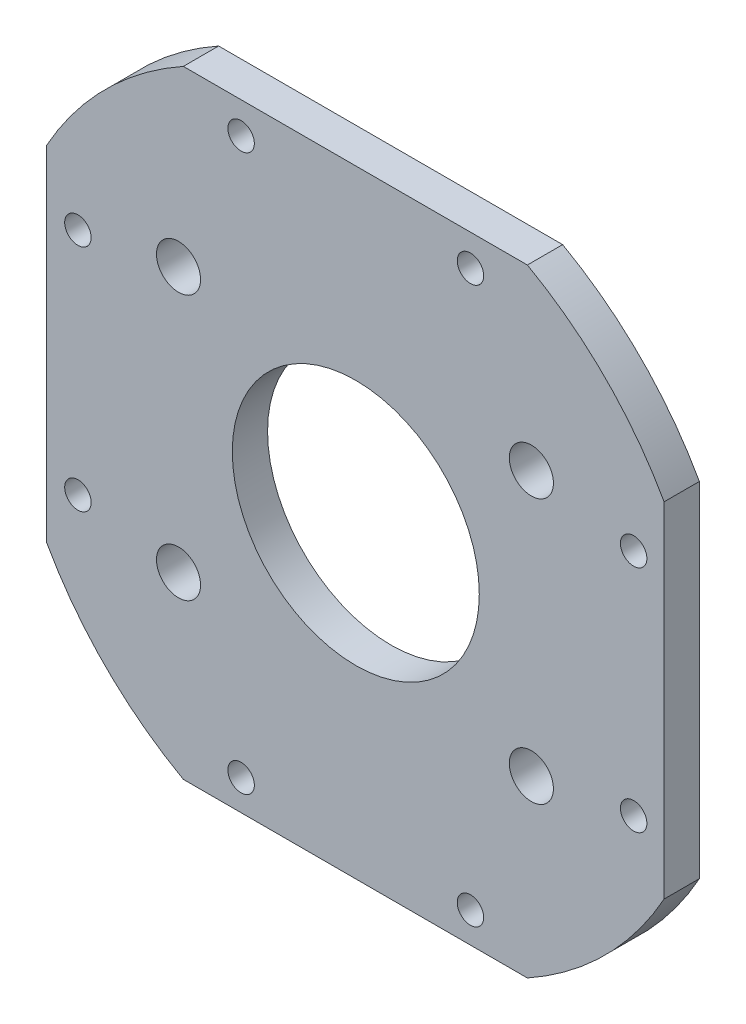
from build123d import *

# Parameters (mm, degrees)
SKETCH1_R           = 2.5
SKETCH1_R_2         = 1.5
SKETCH1_R_3         = 14
BOSS_EXTRUDE1_DEPTH = 4


with BuildPart() as part:
    # Sketch1 → Boss-Extrude1 (new body)
    with BuildSketch(Plane.XY):
        with BuildLine():
            Line((-19.5, 35), (19.5, 35))
            ThreePointArc((19.5, 35), (28.332479027, 28.332479027), (35, 19.5))
            Line((35, 19.5), (35, -19.5))
            ThreePointArc((35, -19.5), (28.332479027, -28.332479027), (19.5, -35))
            Line((19.5, -35), (-19.5, -35))
            ThreePointArc((-19.5, -35), (-28.332479027, -28.332479027), (-35, -19.5))
            Line((-35, -19.5), (-35, 19.5))
            ThreePointArc((-35, 19.5), (-28.332479027, 28.332479027), (-19.5, 35))
        make_face()
        with Locations((-20.04820778, 15.04820778)):
            Circle(SKETCH1_R, mode=Mode.SUBTRACT)
        with Locations((19.95179222, 15.04820778)):
            Circle(SKETCH1_R, mode=Mode.SUBTRACT)
        with Locations((-20.04820778, -14.95179222)):
            Circle(SKETCH1_R, mode=Mode.SUBTRACT)
        with Locations((19.95179222, -14.95179222)):
            Circle(SKETCH1_R, mode=Mode.SUBTRACT)
        with Locations((-12.95179222, 31.45179222)):
            Circle(SKETCH1_R_2, mode=Mode.SUBTRACT)
        with Locations((13.04820778, 31.45179222)):
            Circle(SKETCH1_R_2, mode=Mode.SUBTRACT)
        with Locations((31.54820778, 12.95179222)):
            Circle(SKETCH1_R_2, mode=Mode.SUBTRACT)
        with Locations((31.54820778, -13.04820778)):
            Circle(SKETCH1_R_2, mode=Mode.SUBTRACT)
        with Locations((13.04820778, -31.54820778)):
            Circle(SKETCH1_R_2, mode=Mode.SUBTRACT)
        with Locations((-12.95179222, -31.54820778)):
            Circle(SKETCH1_R_2, mode=Mode.SUBTRACT)
        with Locations((-31.45179222, -13.04820778)):
            Circle(SKETCH1_R_2, mode=Mode.SUBTRACT)
        with Locations((-31.45179222, 12.95179222)):
            Circle(SKETCH1_R_2, mode=Mode.SUBTRACT)
        with Locations((0.04820778, -0.04820778)):
            Circle(SKETCH1_R_3, mode=Mode.SUBTRACT)
    extrude(amount=BOSS_EXTRUDE1_DEPTH)


solid = part.part
